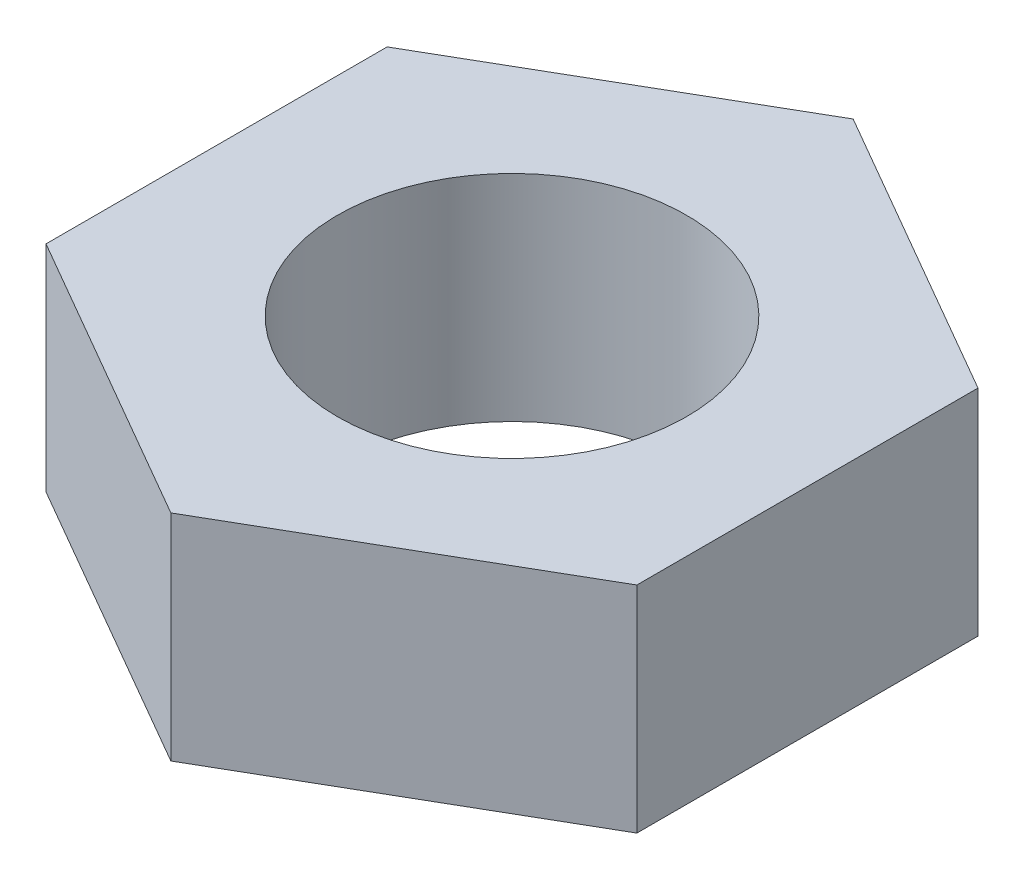
from build123d import *

# Parameters (mm, degrees)
SKIZZE1_R                       = 3.25
AUFSATZ_LINEAR_AUSTRAGEN1_DEPTH = 4


with BuildPart() as part:
    # Skizze1 → Aufsatz-Linear austragen1 (new body)
    with BuildSketch(Plane(origin=(0, 0, 0), x_dir=(1, 0, 0), z_dir=(0, 1, 0))):
        Polygon((5.5, 3.175426481), (0, 6.350852961), (-5.5, 3.175426481), (-5.5, -3.175426481), (0, -6.350852961), (5.5, -3.175426481), align=None)
        Circle(SKIZZE1_R, mode=Mode.SUBTRACT)
    extrude(amount=AUFSATZ_LINEAR_AUSTRAGEN1_DEPTH)


solid = part.part
